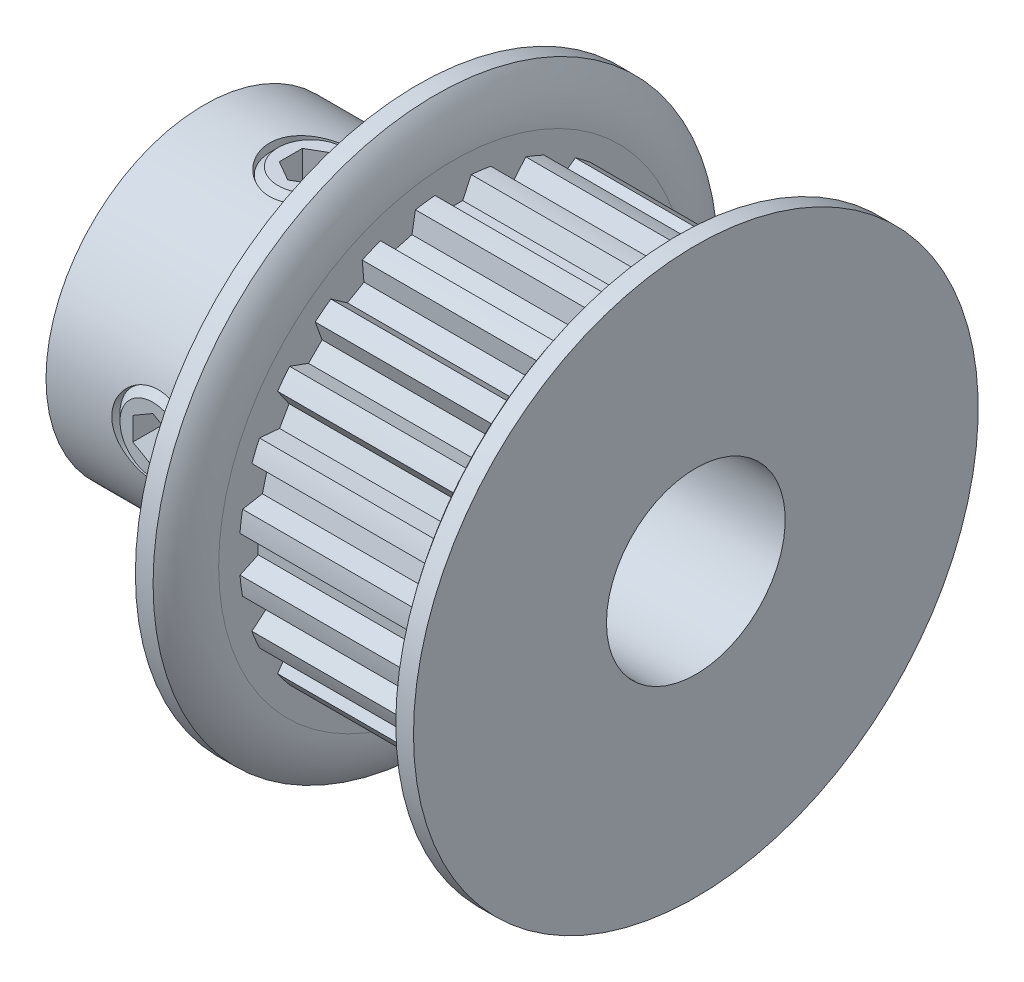
from build123d import *

# Parameters (mm, degrees)
SKETCH4_R          = 7.7597
SKETCH4_R_2        = 7.60095
CUT_EXTRUDE2_DEPTH = 7.366
CUT_EXTRUDE1_DEPTH = 7.366
CIRPATTERN1_COUNT  = 24
SKETCH6_R          = 1.4605
CUT_EXTRUDE3_DEPTH = 17.66336796
CUT_EXTRUDE4_DEPTH = 1.016
CIRPATTERN2_COUNT  = 2
CIRPATTERN2_ANGLE  = 90
CIRPATTERN3_COUNT  = 2
CIRPATTERN3_ANGLE  = 90


with BuildPart() as part:
    # Sketch1 → Revolve1 (revolve)
    with BuildSketch(Plane.XY, mode=Mode.PRIVATE) as revolve1_sk:
        with BuildLine():
            Line((-8.7376, 3.175), (8.7376, 3.175))
            Line((8.7376, 3.175), (8.7376, 10.033))
            Line((8.7376, 10.033), (8.10895, 10.033))
            ThreePointArc((8.10895, 10.033), (7.642486723, 9.238300334), (7.4803, 8.3312))
            Line((7.4803, 8.3312), (7.4803, 7.7597))
            Line((7.4803, 7.7597), (0.1143, 7.7597))
            Line((0.1143, 7.7597), (0.1143, 8.3312))
            ThreePointArc((0.1143, 8.3312), (-0.047886723, 9.238300334), (-0.51435, 10.033))
            Line((-0.51435, 10.033), (-1.143, 10.033))
            Line((-1.143, 10.033), (-1.143, 5.6134))
            Line((-1.143, 5.6134), (-8.7376, 5.6134))
            Line((-8.7376, 5.6134), (-8.7376, 3.175))
        make_face()
    revolve(revolve1_sk.sketch.rotate(Axis((-8.7376, 0, 0), (1, 0, 0)), 90), axis=Axis((-8.7376, 0, 0), (1, 0, 0)))

    # Sketch4 → Cut-Extrude2 (cut)
    with BuildSketch(Plane(origin=(0.1143, 0, 0), x_dir=(0, 0, -1), z_dir=(1, 0, 0))):
        Circle(SKETCH4_R)
        Circle(SKETCH4_R_2, mode=Mode.SUBTRACT)
    extrude(amount=CUT_EXTRUDE2_DEPTH, mode=Mode.SUBTRACT)

    # Sketch3 → Cut-Extrude1 (cut)
    with BuildSketch(Plane(origin=(0.1143, 0, 0), x_dir=(0, 0, -1), z_dir=(1, 0, 0))):
        with BuildLine():
            Line((-0.643066132, 7.57369836), (-0.340952079, 6.925812683))
            Line((-0.340952079, 6.925812683), (0.340952079, 6.925812683))
            Line((0.340952079, 6.925812683), (0.643066132, 7.57369836))
            ThreePointArc((0.643066132, 7.57369836), (0, 7.60095), (-0.643066132, 7.57369836))
        make_face()
    cut_extrude1 = extrude(amount=CUT_EXTRUDE1_DEPTH, mode=Mode.SUBTRACT)

    # CirPattern1: Cut-Extrude1 ×24 about axis
    cirpattern1_axis = Axis((0, 0, 0), (1, 0, 0))
    for i in range(1, CIRPATTERN1_COUNT):
        add(cut_extrude1.rotate(cirpattern1_axis, i * 360 / CIRPATTERN1_COUNT), mode=Mode.SUBTRACT)

    # Sketch6 → Cut-Extrude3 (cut, through all)
    with BuildSketch(Plane(origin=(0, 0, 0), x_dir=(1, 0, 0), z_dir=(0, 1, 0))):
        with Locations(Location((-4.9403, 0, 0), (0, 0, 90))):
            Circle(SKETCH6_R)
    cut_extrude3 = extrude(amount=CUT_EXTRUDE3_DEPTH, mode=Mode.SUBTRACT)

    # CirPattern2: Cut-Extrude3 ×2 about axis
    cirpattern2_axis = Axis((-8.7376, 0, 0), (1, 0, 0))
    for i in range(1, CIRPATTERN2_COUNT):
        add(cut_extrude3.rotate(cirpattern2_axis, i * CIRPATTERN2_ANGLE / (CIRPATTERN2_COUNT - 1)), mode=Mode.SUBTRACT)


with BuildPart() as body_2:
    # Sketch7 → Revolve2 (revolve)
    with BuildSketch(Plane.XY, mode=Mode.PRIVATE) as revolve2_sk:
        Polygon((-6.1087, 5.6134), (-4.9403, 5.6134), (-4.9403, 3.556), (-6.1087, 3.556), (-6.3627, 3.81), (-6.3627, 5.3594), align=None)
    revolve(revolve2_sk.sketch.rotate(Axis((-4.9403, 3.556, 0), (0, 1, 0)), 270), axis=Axis((-4.9403, 3.556, 0), (0, 1, 0)))

    # Sketch8 → Cut-Extrude4 (cut)
    with BuildSketch(Plane(origin=(0, 5.6134, 0), x_dir=(1, 0, 0), z_dir=(0, 1, 0))):
        Polygon((-4.9403, 0.821223023), (-5.6515, 0.410611511), (-5.6515, -0.410611511), (-4.9403, -0.821223023), (-4.2291, -0.410611511), (-4.2291, 0.410611511), align=None)
    extrude(amount=-CUT_EXTRUDE4_DEPTH, mode=Mode.SUBTRACT)


with BuildPart() as cirpattern3_1:
    # CirPattern3: pattern copy
    add(body_2.part.rotate(Axis((0, 0, 0), (1, 0, 0)), 1 * CIRPATTERN3_ANGLE / (CIRPATTERN3_COUNT - 1)))


solid = Compound([part.part, body_2.part, cirpattern3_1.part])
